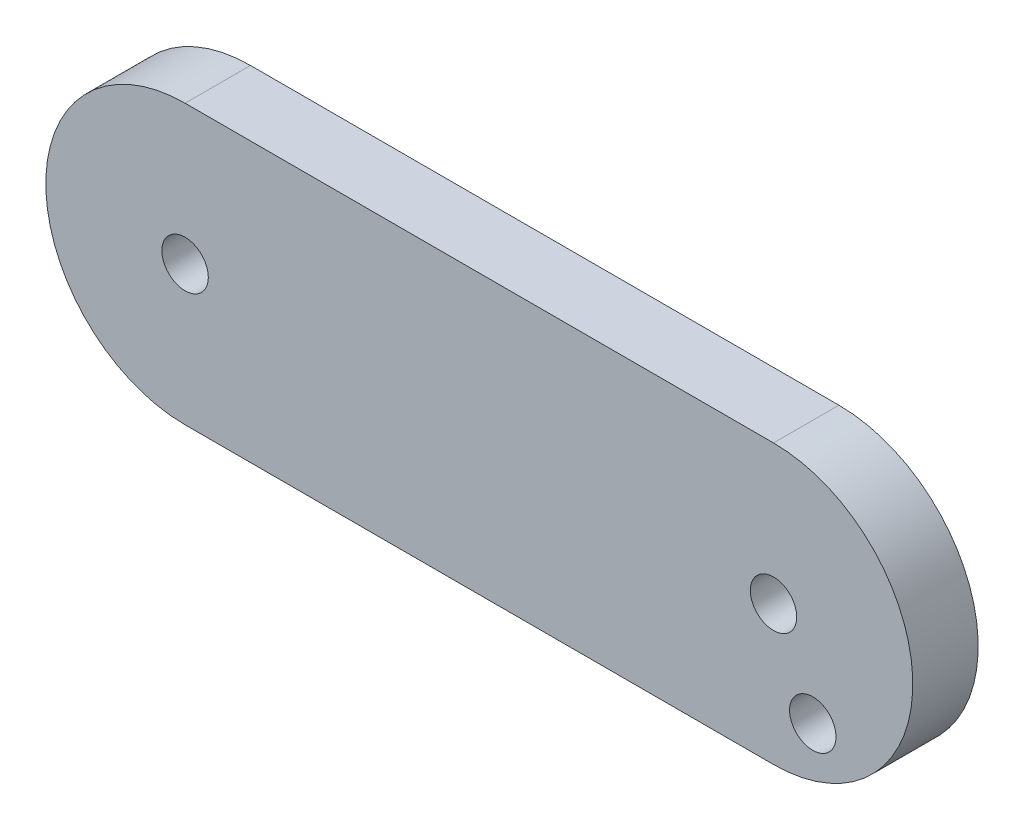
from build123d import *

# Parameters (mm, degrees)
SKETCH1_R           = 0.8875
BOSS_EXTRUDE1_DEPTH = 2.5
SKETCH3_R           = 0.8875
CUT_EXTRUDE2_DEPTH  = 3.5


with BuildPart() as part:
    # Sketch1 → Boss-Extrude1 (new body)
    with BuildSketch(Plane(origin=(-36.53515424, -38.284630008, 568.019288816), x_dir=(1, 0, 0), z_dir=(0, 0, 1))):
        with BuildLine():
            Line((14.03515424, 43.609630008), (36.53515424, 43.609630008))
            ThreePointArc((36.53515424, 43.609630008), (41.86015424, 38.284630008), (36.53515424, 32.959630008))
            Line((36.53515424, 32.959630008), (14.03515424, 32.959630008))
            ThreePointArc((14.03515424, 32.959630008), (8.71015424, 38.284630008), (14.03515424, 43.609630008))
        make_face()
        with Locations((36.53515424, 38.284630008)):
            Circle(SKETCH1_R, mode=Mode.SUBTRACT)
        with Locations((14.03515424, 38.284630008)):
            Circle(SKETCH1_R, mode=Mode.SUBTRACT)
    extrude(amount=BOSS_EXTRUDE1_DEPTH)

    # Sketch3 → Cut-Extrude2 (cut, through all)
    with BuildSketch(Plane(origin=(0, 0, 568.019288816), x_dir=(-1, 0, 0), z_dir=(0, 0, -1))):
        with Locations((-1.50100101, -3.217063252)):
            Circle(SKETCH3_R)
    extrude(amount=-CUT_EXTRUDE2_DEPTH, mode=Mode.SUBTRACT)


solid = part.part
